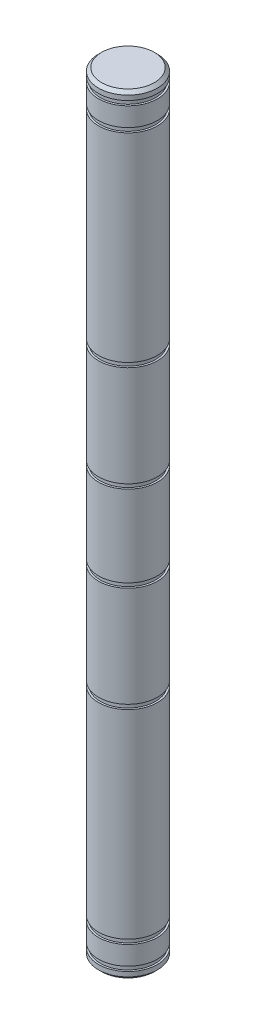
from build123d import *

# Parameters (mm, degrees)
CHAMFER1_SIZE = 0.508


with BuildPart() as part:
    # Sketch1 → Revolve1 (revolve)
    with BuildSketch(Plane.XY):
        Polygon((-4.7625, 60.2234), (-4.7625, 57.1754), (-4.4577, 57.1754), (-4.4577, 56.4388), (-4.7625, 56.4388), (-4.7625, 24.2951), (-4.4577, 24.2951), (-4.4577, 23.5585), (-4.7625, 23.5585), (-4.7625, 7.3025), (-4.4577, 7.3025), (-4.4577, 6.5659), (-4.7625, 6.5659), (-4.7625, -6.5659), (-4.4577, -6.5659), (-4.4577, -7.3025), (-4.7625, -7.3025), (-4.7625, -23.5585), (-4.4577, -23.5585), (-4.4577, -24.2951), (-4.7625, -24.2951), (-4.7625, -56.4388), (-4.4577, -56.4388), (-4.4577, -57.1754), (-4.7625, -57.1754), (-4.7625, -60.2234), (-4.4577, -60.2234), (-4.4577, -60.96), (-4.7625, -60.96), (-4.7625, -62.23), (0, -62.23), (0, 62.23), (-4.7625, 62.23), (-4.7625, 60.96), (-4.4577, 60.96), (-4.4577, 60.2234), align=None)
    revolve(axis=Axis((0, 62.23, 0), (0, -1, 0)))

    # Chamfer1
    chamfer1_edges = [part.edges().sort_by_distance(p)[0] for p in [
        (4.7625, -62.23, 0),
        (4.7625, 62.23, 0),
    ]]
    chamfer(chamfer1_edges, length=CHAMFER1_SIZE)


solid = part.part
